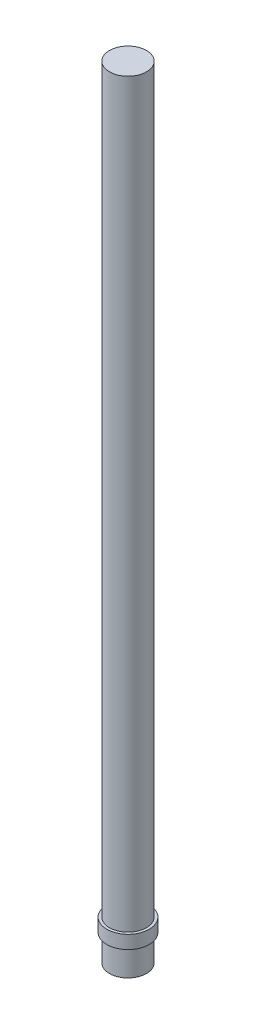
from build123d import *

# Parameters (mm, degrees)
SKETCH1_R           = 3.5
BOSS_EXTRUDE1_DEPTH = 5
SKETCH2_R           = 4
BOSS_EXTRUDE2_DEPTH = 2.5
SKETCH3_R           = 3.5
BOSS_EXTRUDE3_DEPTH = 140


with BuildPart() as part:
    # Sketch1 → Boss-Extrude1 (new body)
    with BuildSketch(Plane(origin=(0, 0, 0), x_dir=(1, 0, 0), z_dir=(0, 1, 0))):
        with Locations(Location((0, 0, 0), (0, 0, 270))):  # turned: the seam where the file's is
            Circle(SKETCH1_R)
    extrude(amount=BOSS_EXTRUDE1_DEPTH)

    # Sketch2 → Boss-Extrude2 (add)
    with BuildSketch(Plane(origin=(0, 5, 0), x_dir=(1, 0, 0), z_dir=(0, 1, 0))):
        with Locations(Location((0, 0, 0), (0, 0, 270))):  # turned: the seam where the file's is
            Circle(SKETCH2_R)
    extrude(amount=BOSS_EXTRUDE2_DEPTH)

    # Sketch3 → Boss-Extrude3 (add)
    with BuildSketch(Plane(origin=(0, 7.5, 0), x_dir=(1, 0, 0), z_dir=(0, 1, 0))):
        with Locations(Location((0, 0, 0), (0, 0, 270))):  # turned: the seam where the file's is
            Circle(SKETCH3_R)
    extrude(amount=BOSS_EXTRUDE3_DEPTH)


solid = part.part
